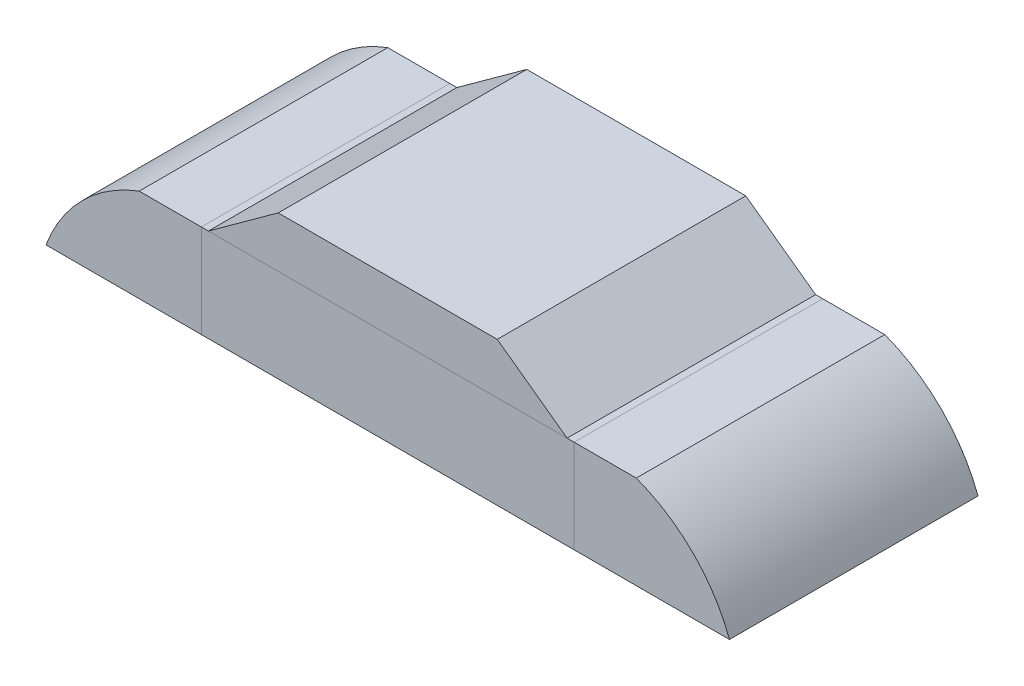
from build123d import *

# Parameters (mm, degrees)
SKETCH1_W           = 1.2
SKETCH1_H           = 0.8
BOSS_EXTRUDE1_DEPTH = 0.3
SKETCH3_W           = 0.2
SKETCH3_H           = 0.1
BOSS_EXTRU_1_DEPTH  = 0.4
BOSS_EXTRUDE5_DEPTH = 0.4


with BuildPart() as part:
    # Sketch1 → Boss-Extrude1 (new body)
    with BuildSketch(Plane(origin=(0, 0, 0), x_dir=(1, 0, 0), z_dir=(0, 1, 0))):
        Rectangle(SKETCH1_W, SKETCH1_H)
    extrude(amount=BOSS_EXTRUDE1_DEPTH)

    # Sketch3 → Revolve1 (revolve)
    with BuildSketch(Plane.XY, mode=Mode.PRIVATE) as revolve1_sk:
        with Locations((0.1, 0.35)):
            Rectangle(SKETCH3_W, SKETCH3_H)
    revolve(revolve1_sk.sketch.rotate(Axis((0, 0.809216282, 0), (0, -1, 0)), 90), axis=Axis((0, 0.809216282, 0), (0, -1, 0)))  # turned: the seam where the file's is


with BuildPart() as body_2:
    # Esquisse1 → Boss.-Extru.1 (new body, symmetric)
    with BuildSketch(Plane.XY):
        with BuildLine():
            Line((-0.6, 0.3), (-0.8, 0.3))
            ThreePointArc((-0.8, 0.3), (-0.982612802, 0.182612802), (-1.1, 0))
            Line((-1.1, 0), (-0.6, 0))
            Line((-0.6, 0), (-0.6, 0.3))
        make_face()
    extrude(amount=BOSS_EXTRU_1_DEPTH, both=True)


with BuildPart() as body_3:
    # Symétrie2: mirrored copy
    add(body_2.part.mirror(Plane(origin=(0, 0, 0), x_dir=(0, 0, 1), z_dir=(1, 0, 0))))


with BuildPart() as body_4:
    # Sketch2 → Boss-Extrude5 (new body, symmetric)
    with BuildSketch(Plane.XY):
        Polygon((0.577336189, 0.3), (-0.577336189, 0.3), (-0.352430123, 0.463036506), (0.352430123, 0.463036506), align=None)
    extrude(amount=BOSS_EXTRUDE5_DEPTH, both=True)


solid = Compound([part.part, body_2.part, body_3.part, body_4.part])
